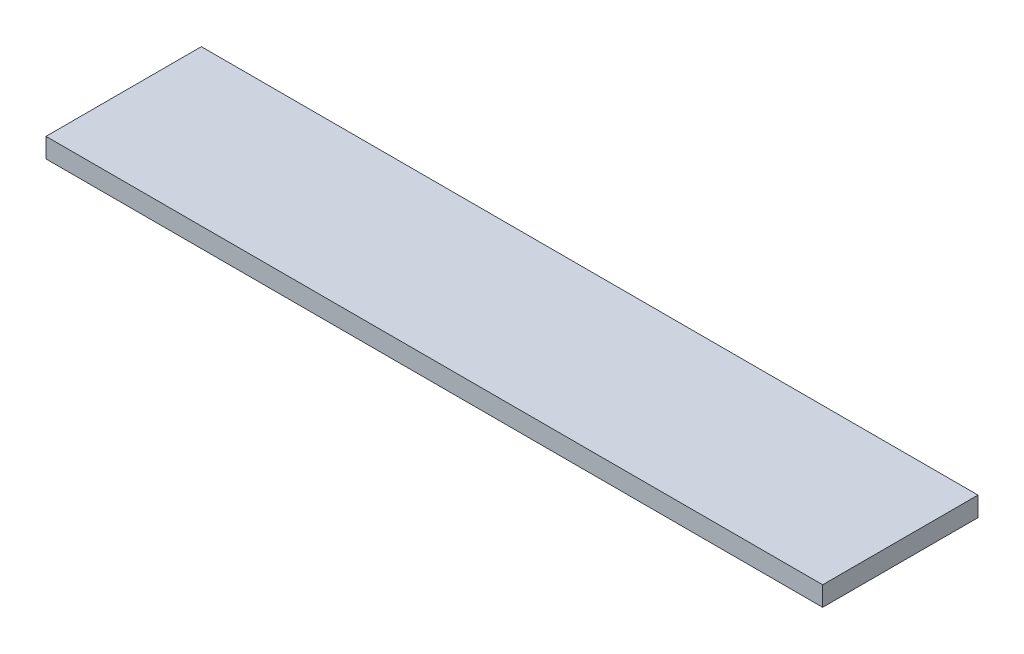
from build123d import *

# Parameters (mm, degrees)
SKETCH1_W           = 63.5
SKETCH1_H           = 12.7
BOSS_EXTRUDE1_DEPTH = 1.6002


with BuildPart() as part:
    # Sketch1 → Boss-Extrude1 (new body)
    with BuildSketch(Plane(origin=(0, 0, 0), x_dir=(1, 0, 0), z_dir=(0, 1, 0))):
        Rectangle(SKETCH1_W, SKETCH1_H)
    extrude(amount=BOSS_EXTRUDE1_DEPTH)


solid = part.part
